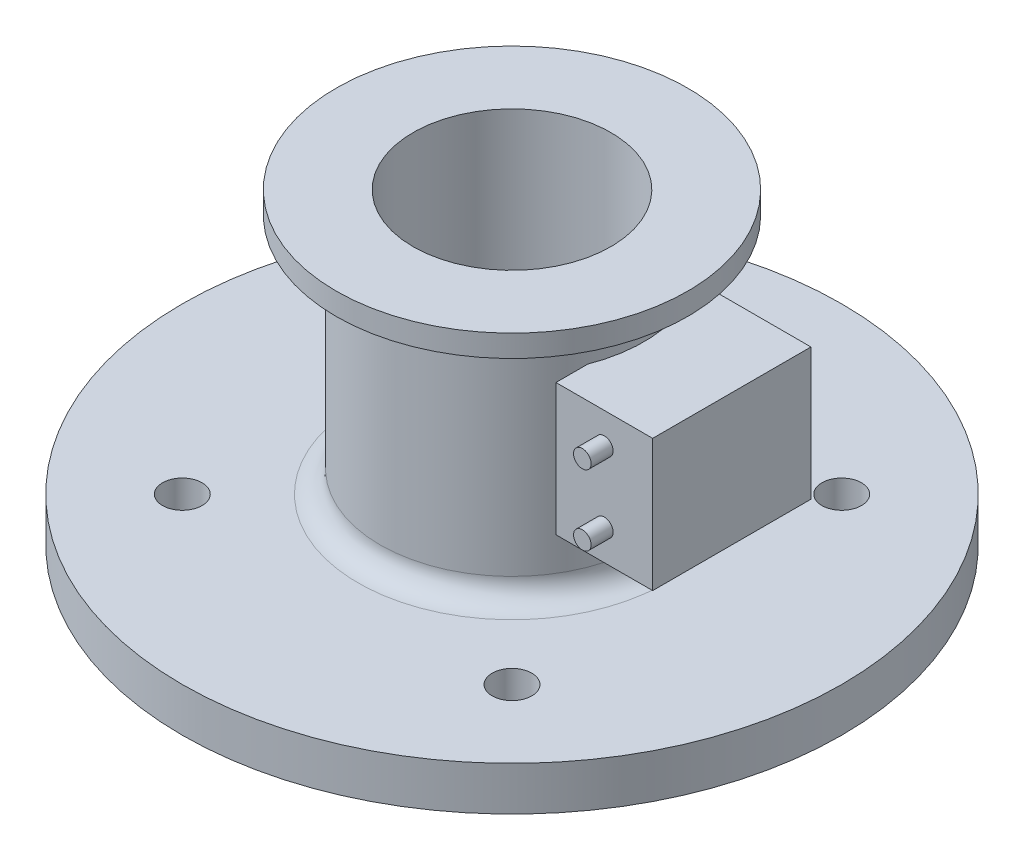
from build123d import *

# Parameters (mm, degrees)
IZIM1_W                     = 100
IZIM1_H                     = 100
IZIM1_R                     = 4.5
Y_KSEKLIK_EKSTR_ZYON1_DEPTH = 10
IZIM3_R                     = 30
IZIM3_R_2                   = 22.5
Y_KSEKLIK_EKSTR_ZYON2_DEPTH = 60
IZIM4_R                     = 40
IZIM4_R_2                   = 30
Y_KSEKLIK_EKSTR_ZYON3_DEPTH = 5
RADYUS1_R                   = 5
Y_KSEKLIK_EKSTR_ZYON4_START = 40
IZIM5_W                     = 22
IZIM5_H                     = 36
Y_KSEKLIK_EKSTR_ZYON4_DEPTH = 15
IZIM6_R                     = 2
Y_KSEKLIK_EKSTR_ZYON5_DEPTH = 5
IZIM7_R                     = 75
Y_KSEKLIK_EKSTR_ZYON6_DEPTH = 10


with BuildPart() as part:
    # Çizim1 → Yükseklik-Ekstrüzyon1 (new body)
    with BuildSketch(Plane(origin=(0, 0, 0), x_dir=(1, 0, 0), z_dir=(0, 1, 0))):
        Rectangle(IZIM1_W, IZIM1_H)
        with Locations((-37.5, 37.5)):
            Circle(IZIM1_R, mode=Mode.SUBTRACT)
        with Locations((37.5, 37.5)):
            Circle(IZIM1_R, mode=Mode.SUBTRACT)
        with Locations((37.5, -37.5)):
            Circle(IZIM1_R, mode=Mode.SUBTRACT)
        with Locations((-37.5, -37.5)):
            Circle(IZIM1_R, mode=Mode.SUBTRACT)
    extrude(amount=Y_KSEKLIK_EKSTR_ZYON1_DEPTH)

    # Çizim3 → Yükseklik-Ekstrüzyon2 (add)
    with BuildSketch(Plane(origin=(0, 10, 0), x_dir=(1, 0, 0), z_dir=(0, 1, 0))):
        Circle(IZIM3_R)
        Circle(IZIM3_R_2, mode=Mode.SUBTRACT)
    extrude(amount=Y_KSEKLIK_EKSTR_ZYON2_DEPTH)

    # Çizim4 → Yükseklik-Ekstrüzyon3 (add)
    with BuildSketch(Plane(origin=(0, 70, 0), x_dir=(1, 0, 0), z_dir=(0, 1, 0))):
        Circle(IZIM4_R)
        Circle(IZIM4_R_2, mode=Mode.SUBTRACT)
    extrude(amount=-Y_KSEKLIK_EKSTR_ZYON3_DEPTH)

    # Radyus1
    radyus1_edges = [part.edges().sort_by_distance(p)[0] for p in [
        (-30, 10, 0),
        (-30, 65, 0),
        (50, 5, 50),
        (-50, 5, 50),
        (-50, 5, -50),
        (50, 5, -50),
    ]]
    fillet(radyus1_edges, radius=RADYUS1_R)

    # Çizim7 → Yükseklik-Ekstrüzyon6 (add)
    with BuildSketch(Plane(origin=(0, 0, 0), x_dir=(1, 0, 0), z_dir=(0, 1, 0))):
        Circle(IZIM7_R)
        with BuildLine():
            Line((45, 50), (-45, 50))
            ThreePointArc((-45, 50), (-48.535533906, 48.535533906), (-50, 45))
            Line((-50, 45), (-50, -45))
            ThreePointArc((-50, -45), (-48.535533906, -48.535533906), (-45, -50))
            Line((-45, -50), (45, -50))
            ThreePointArc((45, -50), (48.535533906, -48.535533906), (50, -45))
            Line((50, -45), (50, 45))
            ThreePointArc((50, 45), (48.535533906, 48.535533906), (45, 50))
        make_face(mode=Mode.SUBTRACT)
    extrude(amount=Y_KSEKLIK_EKSTR_ZYON6_DEPTH)


with BuildPart() as body_2:
    # Çizim5 → Yükseklik-Ekstrüzyon4 (new body, symmetric)
    with BuildSketch(Plane(origin=(0, 0, 0), x_dir=(1, 0, 0), z_dir=(0, 1, 0)).offset(Y_KSEKLIK_EKSTR_ZYON4_START)):
        with Locations((39, 0)):
            Rectangle(IZIM5_W, IZIM5_H)
    extrude(amount=Y_KSEKLIK_EKSTR_ZYON4_DEPTH, both=True)

    # Çizim6 → Yükseklik-Ekstrüzyon5 (add)
    with BuildSketch(Plane.XY.offset(18)):
        with Locations((39, 48)):
            Circle(IZIM6_R)
        with Locations((39, 32)):
            Circle(IZIM6_R)
    extrude(amount=Y_KSEKLIK_EKSTR_ZYON5_DEPTH)


solid = Compound([part.part, body_2.part])
